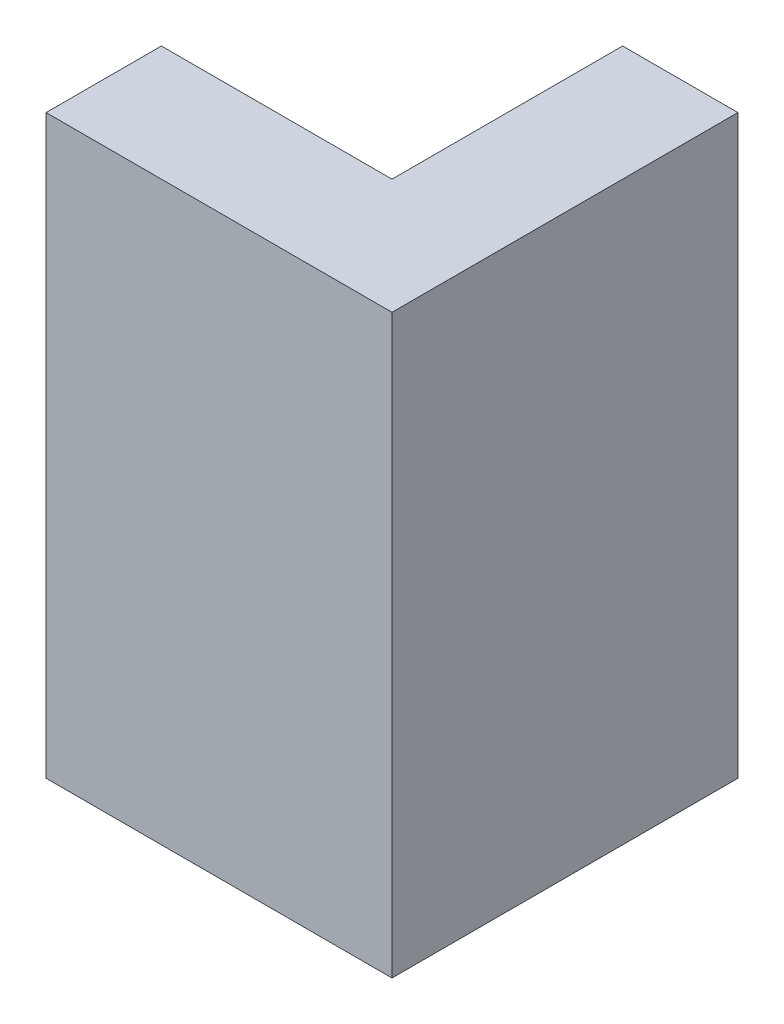
from build123d import *

# Parameters (mm, degrees)
BOSS_EXTRUDE1_DEPTH = 100


with BuildPart() as part:
    # Sketch1 → Boss-Extrude1 (new body)
    with BuildSketch(Plane(origin=(0, 0, 0), x_dir=(1, 0, 0), z_dir=(0, 1, 0))):
        Polygon((60, 0), (60, 60), (40, 60), (40, 20), (0, 20), (0, 0), align=None)
    extrude(amount=BOSS_EXTRUDE1_DEPTH)


solid = part.part
